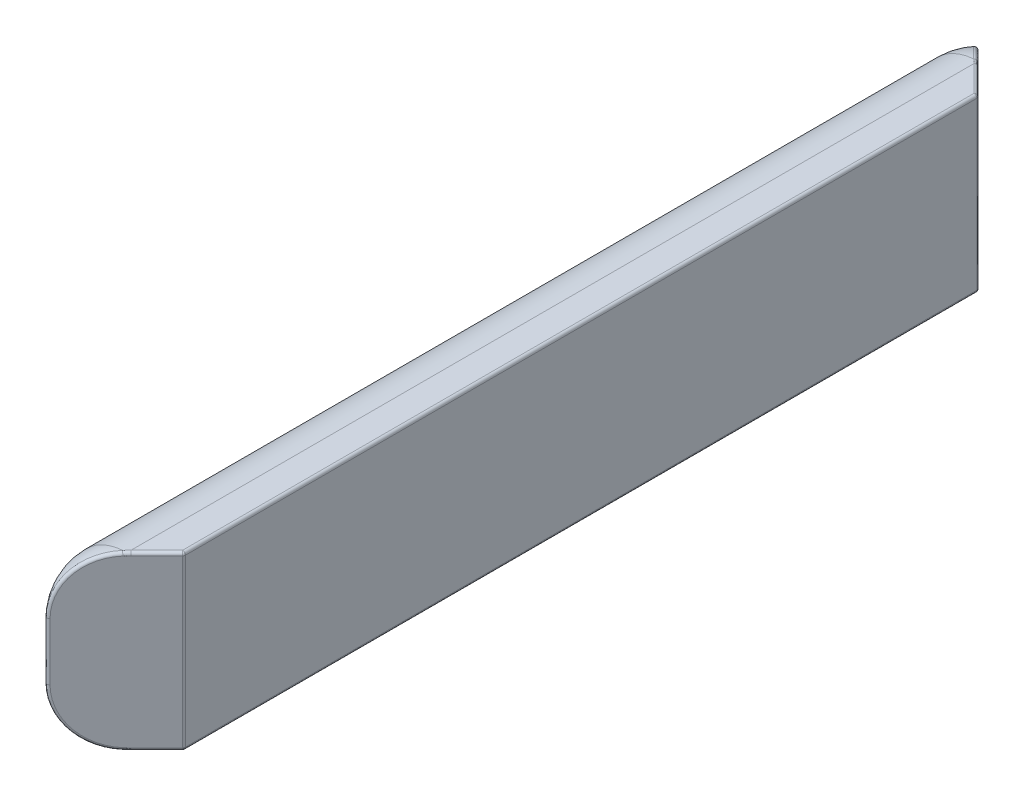
from build123d import *

# Parameters (mm, degrees)
SKETCH1_W           = 927.1
SKETCH1_H           = 855.98
BOSS_EXTRUDE1_DEPTH = 152.4
FILLET1_R           = 50.8
SKETCH3_W           = 774.7
SKETCH3_H           = 703.58
CUT_EXTRUDE1_DEPTH  = 152.4
CUT_EXTRUDE2_DEPTH  = 153.4
FILLET2_R           = 2.54


with BuildPart() as part:
    # Sketch1 → Boss-Extrude1 (new body)
    with BuildSketch(Plane(origin=(0, 0, 0), x_dir=(1, 0, 0), z_dir=(0, 1, 0))):
        Rectangle(SKETCH1_W, SKETCH1_H)
    extrude(amount=BOSS_EXTRUDE1_DEPTH)

    # Fillet1
    fillet1_edges = [part.edges().sort_by_distance(p)[0] for p in [
        (-463.55, 152.4, 0),
        (0, 152.4, 427.99),
        (463.55, 152.4, 0),
        (0, 0, 427.99),
        (-463.55, 0, 0),
        (0, 0, -427.99),
        (463.55, 0, 0),
        (0, 152.4, -427.99),
        (463.55, 76.2, 427.99),
        (-463.55, 76.2, 427.99),
        (-463.55, 76.2, -427.99),
        (463.55, 76.2, -427.99),
    ]]
    fillet(fillet1_edges, radius=FILLET1_R)

    # Sketch3 → Cut-Extrude1 (cut)
    with BuildSketch(Plane(origin=(0, 152.4, 0), x_dir=(1, 0, 0), z_dir=(0, 1, 0))):
        Rectangle(SKETCH3_W, SKETCH3_H)
    extrude(amount=-CUT_EXTRUDE1_DEPTH, mode=Mode.SUBTRACT)

    # Sketch4 → Cut-Extrude2 (cut, through all)
    with BuildSketch(Plane(origin=(0, 152.4, 0), x_dir=(1, 0, 0), z_dir=(0, 1, 0))):
        Polygon((-387.35, 351.79), (-463.55, 427.99), (463.55, 427.99), (463.55, -427.99), (-463.55, -427.99), (-387.35, -351.79), align=None)
    extrude(amount=-CUT_EXTRUDE2_DEPTH, mode=Mode.SUBTRACT)

    # Fillet2
    fillet2_edges = [part.edges().sort_by_distance(p)[0] for p in [
        (-387.35, 0, 0),
        (-387.35, 76.2, 351.79),
        (-387.35, 76.2, -351.79),
        (-387.35, 152.4, 0),
        (-448.671024484, 76.2, 413.111024484),
        (-438.15, 14.878975516, 402.59),
        (-438.15, 137.521024484, 402.59),
        (-438.15, 14.878975516, -402.59),
        (-448.671024484, 76.2, -413.111024484),
        (-438.15000035, 137.521023989, -402.59000035),
        (-400.05, 152.4, -364.49),
        (-400.05, 152.4, 364.49),
        (-400.05, 0, -364.49),
        (-400.05, 0, 364.49),
    ]]
    fillet(fillet2_edges, radius=FILLET2_R)


solid = part.part
